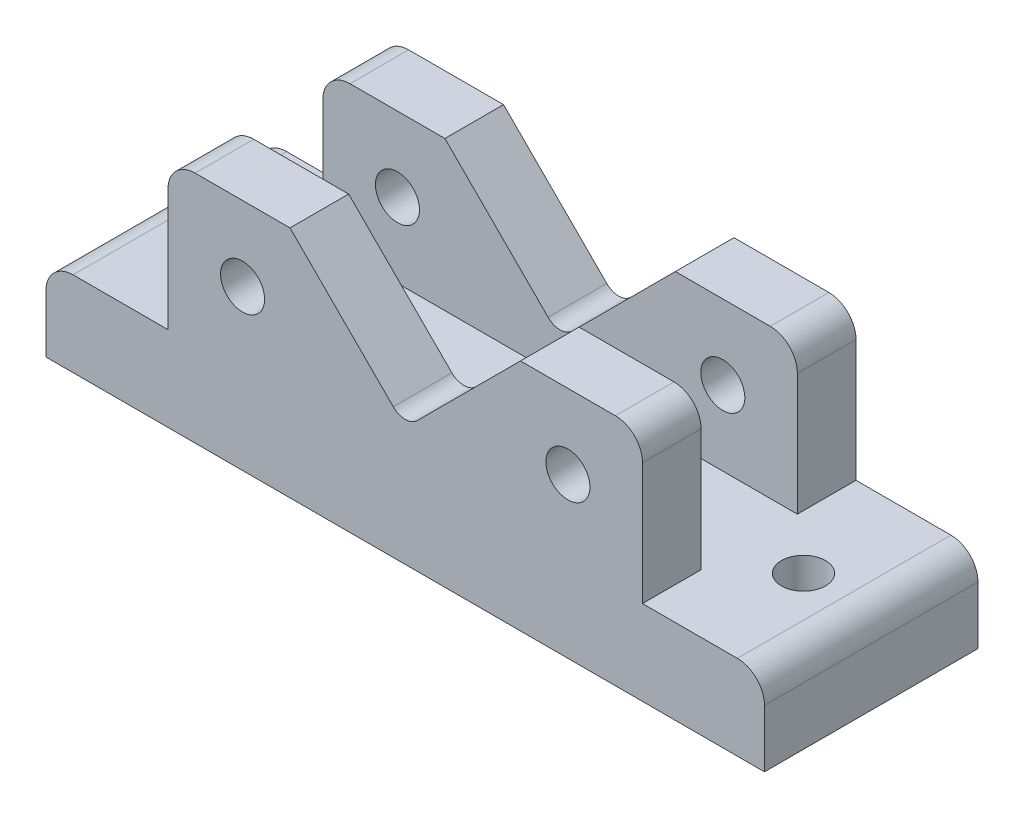
from build123d import *

# Parameters (mm, degrees)
SKETCH1_W           = 212
SKETCH1_H           = 63
SKETCH1_R           = 6.5
BOSS_EXTRUDE1_DEPTH = 25
SKETCH2_R           = 6.5
BOSS_EXTRUDE2_DEPTH = 17.3
FILLET1_R           = 8
FILLET2_R           = 5


with BuildPart() as part:
    # Sketch1 → Boss-Extrude1 (new body)
    with BuildSketch(Plane(origin=(0, 0, 0), x_dir=(1, 0, 0), z_dir=(0, 1, 0))):
        Rectangle(SKETCH1_W, SKETCH1_H)
        with Locations((86, 0)):
            Circle(SKETCH1_R, mode=Mode.SUBTRACT)
        with Locations((-86, 0)):
            Circle(SKETCH1_R, mode=Mode.SUBTRACT)
    extrude(amount=BOSS_EXTRUDE1_DEPTH)

    # Sketch2 → Boss-Extrude2 (add)
    with BuildSketch(Plane.XY.offset(31.5)):
        with BuildLine():
            Line((-70, 25), (70, 25))
            Line((70, 25), (70, 61))
            ThreePointArc((70, 61), (67.656854249, 66.656854249), (62, 69))
            Line((62, 69), (34, 69))
            Line((34, 69), (0, 35))
            Line((0, 35), (-34, 69))
            Line((-34, 69), (-62, 69))
            ThreePointArc((-62, 69), (-67.656854249, 66.656854249), (-70, 61))
            Line((-70, 61), (-70, 25))
        make_face()
        with Locations((-48, 47)):
            Circle(SKETCH2_R, mode=Mode.SUBTRACT)
        with Locations((48, 47)):
            Circle(SKETCH2_R, mode=Mode.SUBTRACT)
    boss_extrude2 = extrude(amount=-BOSS_EXTRUDE2_DEPTH)

    # Mirror1: Boss-Extrude2 across plane
    add(boss_extrude2.mirror(Plane.XY))

    # Fillet1
    fillet1_edges = [part.edges().sort_by_distance(p)[0] for p in [
        (-106, 25, 0),
        (106, 25, 0),
    ]]
    fillet(fillet1_edges, radius=FILLET1_R)

    # Fillet2
    fillet2_edges = [part.edges().sort_by_distance(p)[0] for p in [
        (0, 35, 22.85),
        (0, 35, -22.85),
    ]]
    fillet(fillet2_edges, radius=FILLET2_R)


solid = part.part
